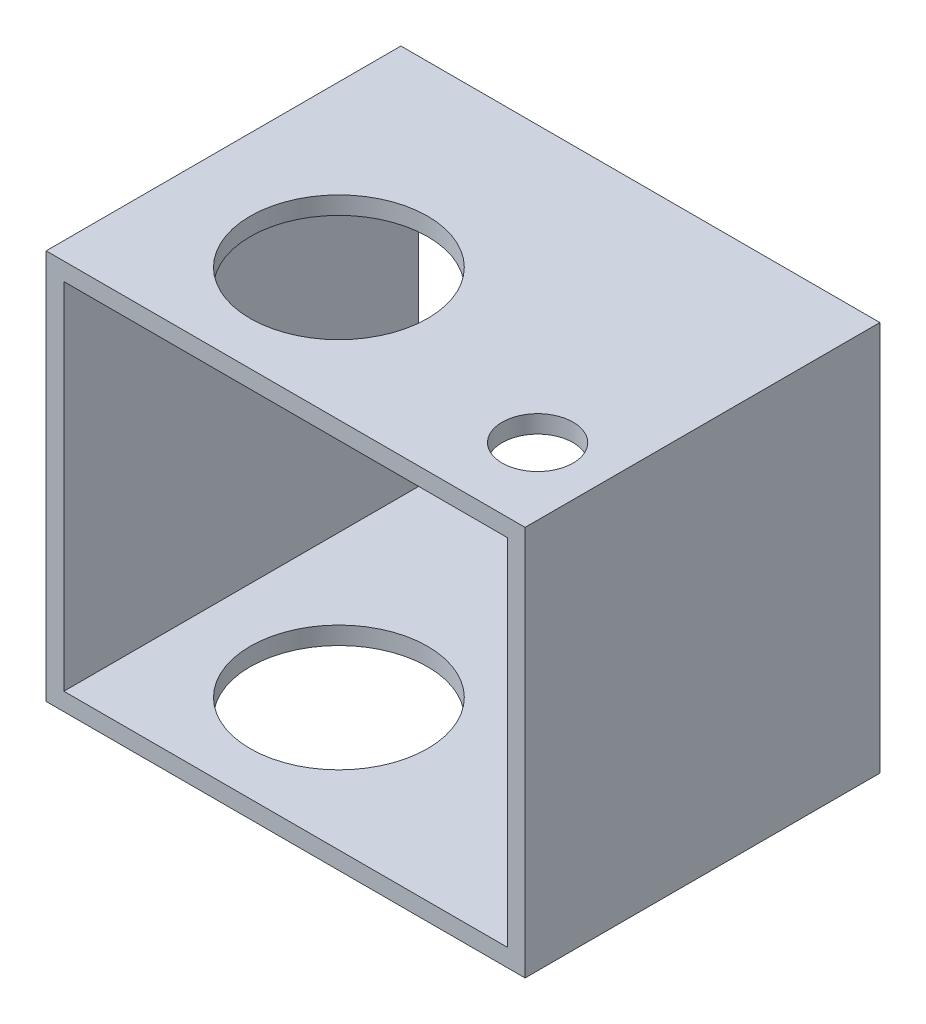
from build123d import *

# Parameters (mm, degrees)
ESBO_O1_W             = 27
ESBO_O1_H             = 22
ESBO_O1_W_2           = 25
ESBO_O1_H_2           = 20
EXTRUS_O_FINA1_DEPTH  = 20
ESBO_O2_R             = 5
CORTE_EXTRUS_O1_DEPTH = 23
ESBO_O3_R             = 2
CORTE_EXTRUS_O2_DEPTH = 10


with BuildPart() as part:
    # Esboço1 → Extrusão-Fina1 (new body)
    with BuildSketch(Plane.XY):
        with Locations((-12.5, 10)):
            Rectangle(ESBO_O1_W, ESBO_O1_H)
        with Locations((-12.5, 10)):
            Rectangle(ESBO_O1_W_2, ESBO_O1_H_2, mode=Mode.SUBTRACT)
    extrude(amount=EXTRUS_O_FINA1_DEPTH)

    # Esboço2 → Corte-extrusão1 (cut, through all)
    with BuildSketch(Plane(origin=(0, 21, 0), x_dir=(1, 0, 0), z_dir=(0, 1, 0))):
        with Locations(Location((-16.944433868, -12.551828058, 0), (0, 0, 180))):  # turned: the seam where the file's is
            Circle(ESBO_O2_R)
    extrude(amount=-CORTE_EXTRUS_O1_DEPTH, mode=Mode.SUBTRACT)

    # Esboço3 → Corte-extrusão2 (cut)
    with BuildSketch(Plane(origin=(0, 21, 0), x_dir=(1, 0, 0), z_dir=(0, 1, 0))):
        with Locations(Location((-2.78489643, -15.508719635, 0), (0, 0, 180))):  # turned: the seam where the file's is
            Circle(ESBO_O3_R)
    extrude(amount=-CORTE_EXTRUS_O2_DEPTH, mode=Mode.SUBTRACT)


solid = part.part
